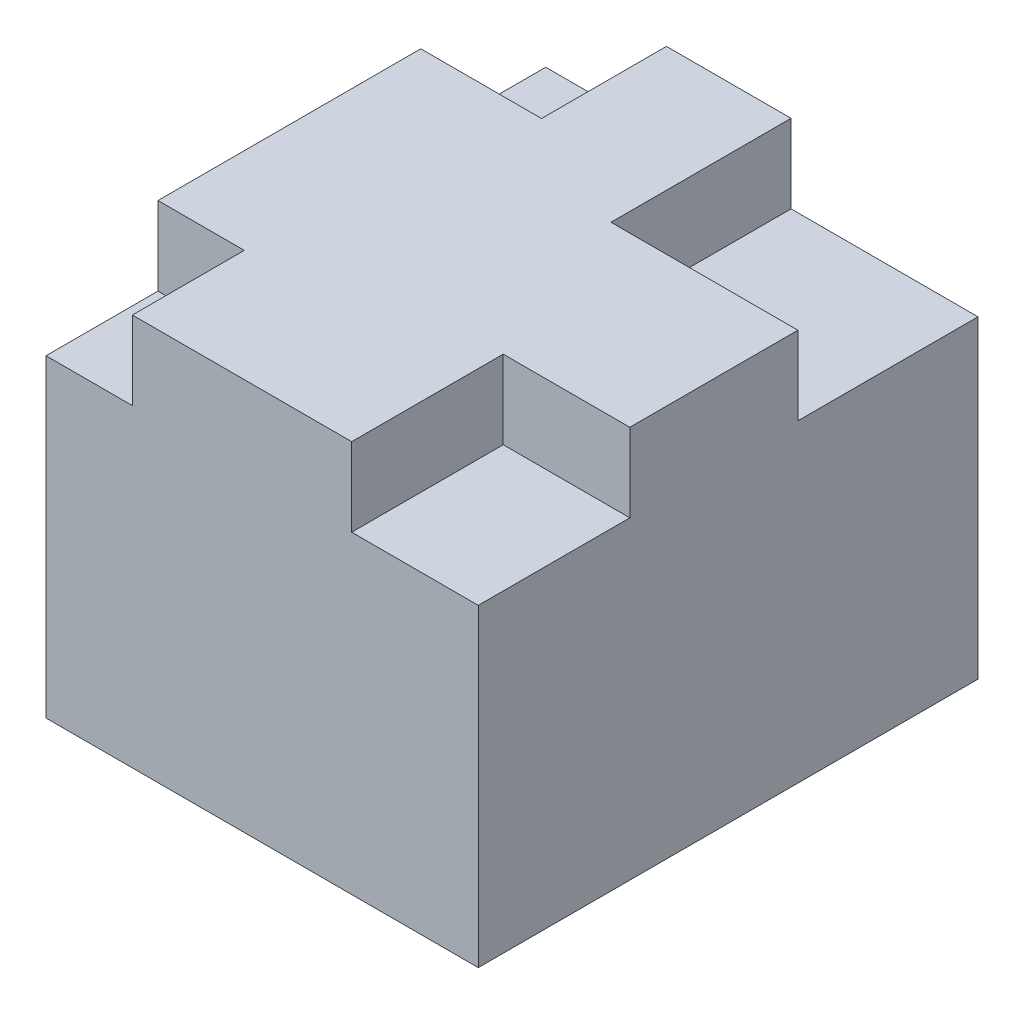
from build123d import *

# Parameters (mm, degrees)
SKETCH1_W           = 11.021234102
SKETCH1_H           = 12.740456306
BOSS_EXTRUDE1_DEPTH = 10
SKETCH2_W           = 2.201611783
SKETCH2_H           = 2.854410055
SKETCH2_W_2         = 3.227403416
SKETCH2_H_2         = 3.863656662
SKETCH2_W_3         = 3.078498179
SKETCH2_H_3         = 3.185310582
SKETCH2_W_4         = 4.766090866
SKETCH2_H_4         = 4.591637821
CUT_EXTRUDE1_DEPTH  = 2
SKETCH3_W           = 4.20243669
SKETCH3_H           = 4.351341928
CUT_EXTRUDE2_DEPTH  = 5


with BuildPart() as part:
    # Sketch1 → Boss-Extrude1 (new body)
    with BuildSketch(Plane(origin=(0, 0, 0), x_dir=(1, 0, 0), z_dir=(0, 1, 0))):
        Rectangle(SKETCH1_W, SKETCH1_H)
    extrude(amount=BOSS_EXTRUDE1_DEPTH)

    # Sketch2 → Cut-Extrude1 (cut)
    with BuildSketch(Plane(origin=(0, 10, 0), x_dir=(1, 0, 0), z_dir=(0, 1, 0))):
        with Locations((-4.40981116, -4.943023125)):
            Rectangle(SKETCH2_W, SKETCH2_H)
        with Locations((3.896915343, -4.438399822)):
            Rectangle(SKETCH2_W_2, SKETCH2_H_2)
        with Locations((-3.971367962, 4.777572862)):
            Rectangle(SKETCH2_W_3, SKETCH2_H_3)
        with Locations((3.127571618, 4.074409242)):
            Rectangle(SKETCH2_W_4, SKETCH2_H_4)
    extrude(amount=-CUT_EXTRUDE1_DEPTH, mode=Mode.SUBTRACT)

    # Sketch3 → Cut-Extrude2 (cut)
    with BuildSketch(Plane.XZ):
        Rectangle(SKETCH3_W, SKETCH3_H)
    extrude(amount=-CUT_EXTRUDE2_DEPTH, mode=Mode.SUBTRACT)


solid = part.part
